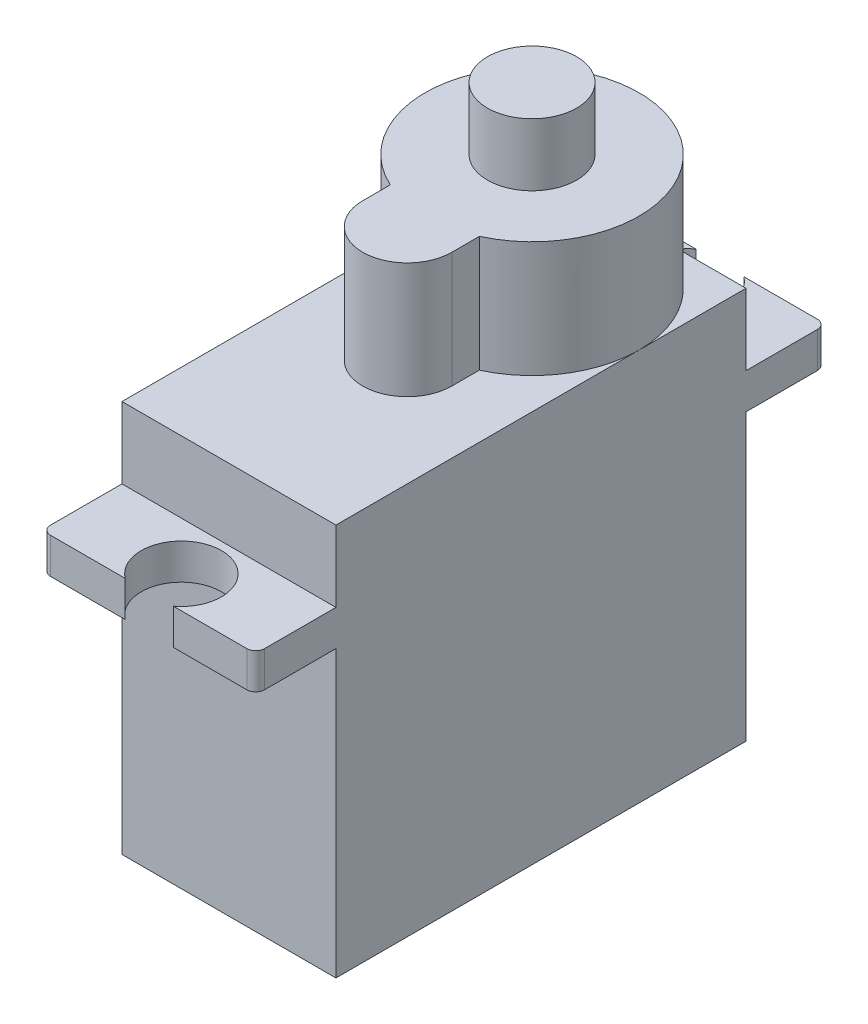
from build123d import *

# Parameters (mm, degrees)
SKETCH4_R           = 2.5
BOSS_EXTRUDE2_DEPTH = 32
BOSS_EXTRUDE3_DEPTH = 28.5
SKETCH1_W           = 12
SKETCH1_H           = 23
BOSS_EXTRUDE4_DEPTH = 22
BOSS_EXTRUDE6_DEPTH = 2
FILLET2_R           = 0.5


with BuildPart() as part:
    # Sketch4 → Boss-Extrude2 (new body)
    with BuildSketch(Plane(origin=(0, 0, 0), x_dir=(1, 0, 0), z_dir=(0, 1, 0))):
        with Locations((51.314367453, -99.151596437)):
            Circle(SKETCH4_R)
    extrude(amount=BOSS_EXTRUDE2_DEPTH)

    # Sketch3 → Boss-Extrude3 (add)
    with BuildSketch(Plane(origin=(0, 0, 0), x_dir=(1, 0, 0), z_dir=(0, 1, 0))):
        with BuildLine():
            Line((48.814367453, -106.151596437), (48.814367453, -104.605952495))
            ThreePointArc((48.814367453, -104.605952495), (51.314367453, -93.151596437), (53.814367453, -104.605952495))
            Line((53.814367453, -104.605952495), (53.814367453, -106.151596437))
            ThreePointArc((53.814367453, -106.151596437), (51.314367453, -108.651596437), (48.814367453, -106.151596437))
        make_face()
    extrude(amount=BOSS_EXTRUDE3_DEPTH)

    # Sketch1 → Boss-Extrude4 (add)
    with BuildSketch(Plane(origin=(0, 0, 0), x_dir=(1, 0, 0), z_dir=(0, 1, 0))):
        with Locations((51.314367453, -104.651596437)):
            Rectangle(SKETCH1_W, SKETCH1_H)
    extrude(amount=BOSS_EXTRUDE4_DEPTH)

    # Sketch7 → Boss-Extrude6 (add)
    with BuildSketch(Plane(origin=(0, 16, 0), x_dir=(1, 0, 0), z_dir=(0, 1, 0))):
        with BuildLine():
            Line((52.694479243, -120.651596437), (57.314367453, -120.651596437))
            Line((57.314367453, -120.651596437), (57.314367453, -116.151596437))
            Line((57.314367453, -116.151596437), (45.314367453, -116.151596437))
            Line((45.314367453, -116.151596437), (45.314367453, -120.651596437))
            Line((45.314367453, -120.651596437), (49.994479243, -120.651596437))
            ThreePointArc((49.994479243, -120.651596437), (51.344479243, -116.601596437), (52.694479243, -120.651596437))
        make_face()
        with BuildLine():
            Line((45.314367453, -93.151596437), (57.314367453, -93.151596437))
            Line((57.314367453, -93.151596437), (57.314367453, -88.651596437))
            Line((57.314367453, -88.651596437), (52.694479243, -88.651596437))
            ThreePointArc((52.694479243, -88.651596437), (51.344479243, -92.701596437), (49.994479243, -88.651596437))
            Line((49.994479243, -88.651596437), (45.314367453, -88.651596437))
            Line((45.314367453, -88.651596437), (45.314367453, -93.151596437))
        make_face()
    extrude(amount=BOSS_EXTRUDE6_DEPTH)

    # Fillet2
    fillet2_edges = [part.edges().sort_by_distance(p)[0] for p in [
        (45.314367453, 17, 120.651596437),
        (57.314367453, 17, 120.651596437),
        (45.314367453, 17, 88.651596437),
        (57.314367453, 17, 88.651596437),
    ]]
    fillet(fillet2_edges, radius=FILLET2_R)


solid = part.part
